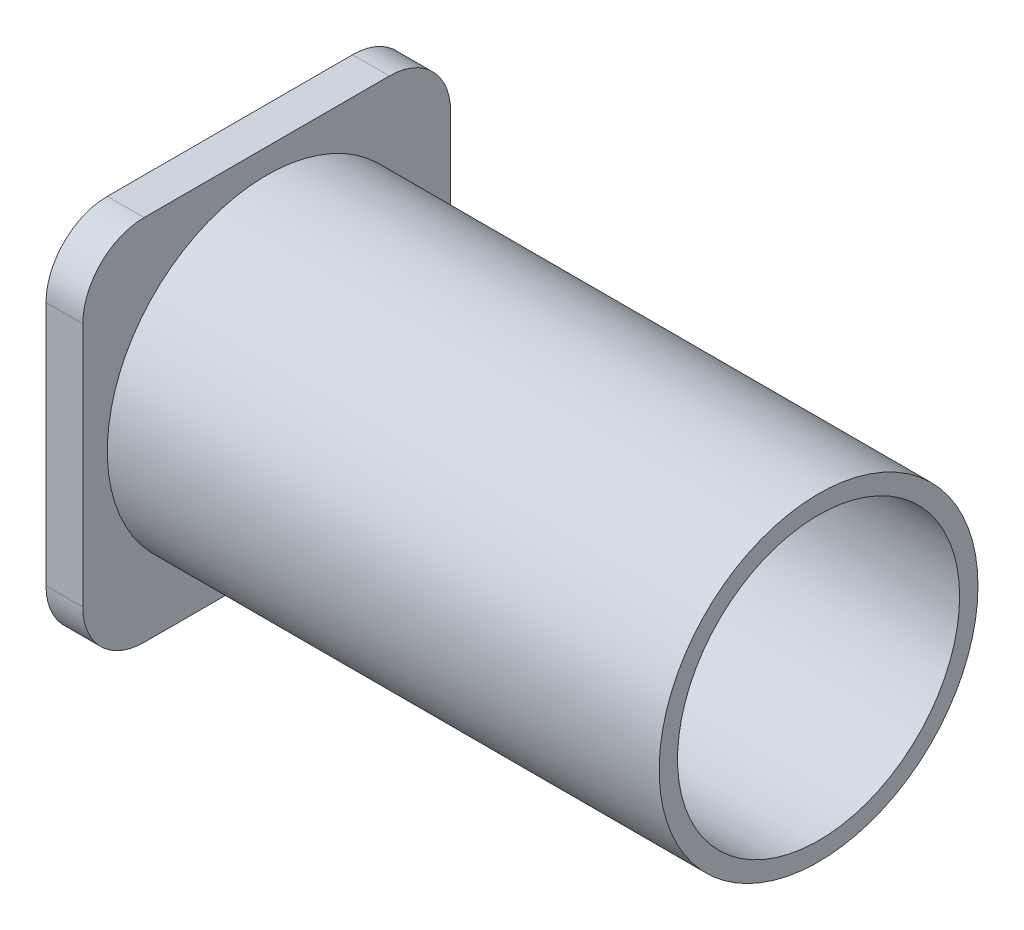
from build123d import *

# Parameters (mm, degrees)
SKETCH1_R           = 13
SKETCH1_R_2         = 11.5
BOSS_EXTRUDE5_DEPTH = 45
BOSS_EXTRUDE7_DEPTH = 3


with BuildPart() as part:
    # Sketch1 → Boss-Extrude5 (new body)
    with BuildSketch(Plane(origin=(0, 0, 0), x_dir=(0, 0, -1), z_dir=(1, 0, 0))):
        Circle(SKETCH1_R)
        Circle(SKETCH1_R_2, mode=Mode.SUBTRACT)
    extrude(amount=BOSS_EXTRUDE5_DEPTH)

    # Sketch5 → Boss-Extrude7 (add)
    with BuildSketch(Plane.ZY):
        with BuildLine():
            Line((-10, 15), (10, 15))
            ThreePointArc((10, 15), (13.535533906, 13.535533906), (15, 10))
            Line((15, 10), (15, -10))
            ThreePointArc((15, -10), (13.535533906, -13.535533906), (10, -15))
            Line((10, -15), (-10, -15))
            ThreePointArc((-10, -15), (-13.535533906, -13.535533906), (-15, -10))
            Line((-15, -10), (-15, 10))
            ThreePointArc((-15, 10), (-13.535533906, 13.535533906), (-10, 15))
        make_face()
    extrude(amount=BOSS_EXTRUDE7_DEPTH)


solid = part.part
